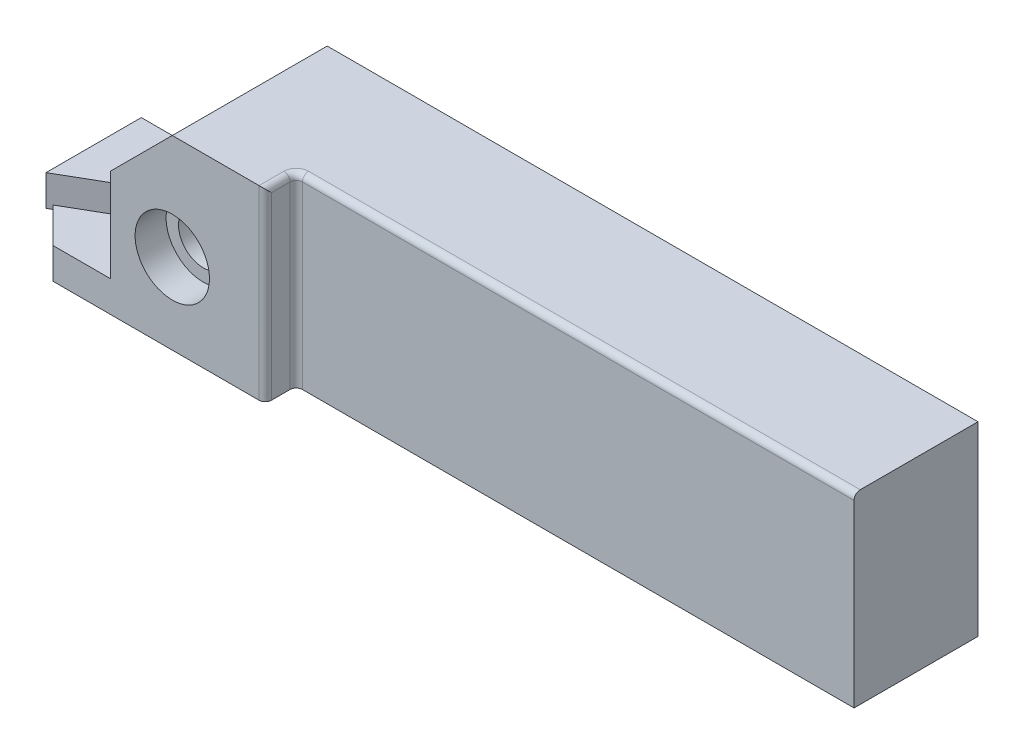
from build123d import *

# Parameters (mm, degrees)
SKETCH_1_W                = 110
SKETCH_1_H                = 30
EXTRUDE_1_DEPTH           = 20
EXTRUDE_2_DEPTH           = 5
EXTRUDE_2_DEPTH_BACK      = 20
FILLET_1_R                = 1
CUT_EXTRUDE_1_DEPTH       = 20
HOLE_WIZARD_1_D           = 8
HOLE_WIZARD_1_DEPTH       = 20
HOLE_WIZARD_1_CBORE_D     = 12
HOLE_WIZARD_1_CBORE_DEPTH = 5
CUT_EXTRUDE_2_REACH       = 32
SKETCH_7_W                = 20
SKETCH_7_H                = 20


with BuildPart() as part:
    # 草图1 → 凸台-拉伸1 (new body)
    with BuildSketch(Plane.XY):
        with Locations((-5, 0)):
            Rectangle(SKETCH_1_W, SKETCH_1_H)
    extrude(amount=EXTRUDE_1_DEPTH)

    # 草图3 → 凸台-拉伸2 (add, two sides)
    with BuildSketch(Plane.XY.offset(20)) as extrude_2_sk:
        Polygon((-60, -15), (-60, 15), (-75, 15), (-85, 5), (-85, -10), (-105, -10), (-105, -15), align=None)
    extrude(amount=EXTRUDE_2_DEPTH)
    extrude(extrude_2_sk.sketch, amount=-EXTRUDE_2_DEPTH_BACK)

    # 圆角1
    fillet_1_edges = [part.edges().sort_by_distance(p)[0] for p in [
        (-60, 15, 22.5),
        (-60, 0, 25),
        (-60, 0, 20),
        (-5, 15, 20),
    ]]
    fillet(fillet_1_edges, radius=FILLET_1_R)

    # 草图4 → 切除-拉伸1 (cut)
    with BuildSketch(Plane.XZ.offset(15)):
        with BuildLine():
            Line((-94.259340252, 25), (-99.916194502, 19.343145751))
            Line((-99.916194502, 19.343145751), (-90.484708185, 13.897874587))
            Line((-90.484708185, 13.897874587), (-77.622420706, 13.897874587))
            ThreePointArc((-77.622420706, 13.897874587), (-72.004883636, 12.451966115), (-77.602894826, 10.932214568))
            Line((-77.602894826, 10.932214568), (-92.230981332, 10.932214568))
            Line((-92.230981332, 10.932214568), (-90.609831702, 7.106640556))
            ThreePointArc((-90.609831702, 7.106640556), (-91.670953588, 4.484805255), (-94.292788888, 5.545927141))
            Line((-94.292788888, 5.545927141), (-96.339745962, 10.376317651))
            Line((-96.339745962, 10.376317651), (-105, 15.376317651))
            Line((-105, 15.376317651), (-105, 25))
            Line((-105, 25), (-94.259340252, 25))
        make_face()
    extrude(amount=-CUT_EXTRUDE_1_DEPTH, mode=Mode.SUBTRACT)

    # 孔1
    with Locations(Plane(origin=(-75, -2, 25), x_dir=(1, 0, 0), z_dir=(0, 0, 1))):
        with Locations((0, 0)):
            CounterBoreHole(HOLE_WIZARD_1_D / 2, HOLE_WIZARD_1_CBORE_D / 2, HOLE_WIZARD_1_CBORE_DEPTH, depth=HOLE_WIZARD_1_DEPTH)

    # 草图7 → 切除-拉伸2 (cut, up to next)
    with BuildSketch(Plane(origin=(0, -15, 0), x_dir=(-1, 0, 0), z_dir=(0, -1, 0)), mode=Mode.PRIVATE) as cut_extrude_2_sk1:
        with Locations((-40, -10)):
            Rectangle(SKETCH_7_W, SKETCH_7_H)
    cut_extrude_2_tool1 = extrude(cut_extrude_2_sk1.sketch, amount=-CUT_EXTRUDE_2_REACH, mode=Mode.PRIVATE) & part.part
    add(cut_extrude_2_tool1.solids().sort_by_distance((40, -15, 10))[0], mode=Mode.SUBTRACT)


solid = part.part
